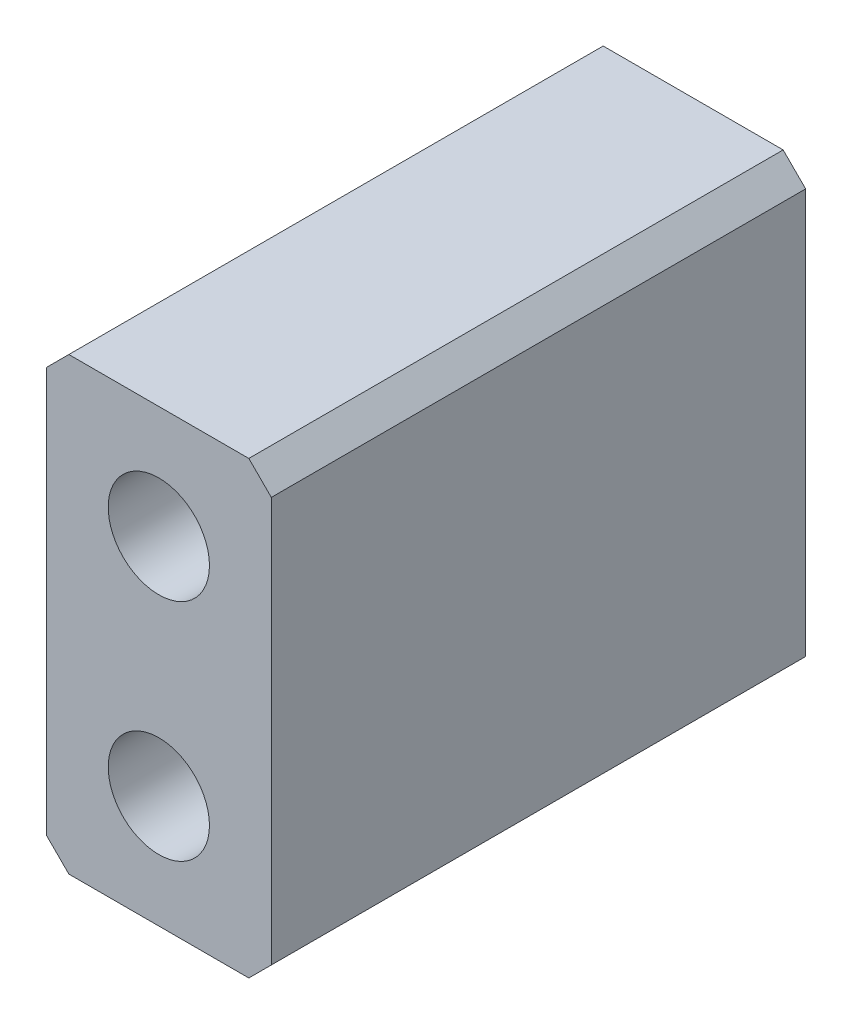
from build123d import *

# Parameters (mm, degrees)
SKETCH_1_W      = 20
SKETCH_1_H      = 40
SKETCH_1_R      = 4.5
EXTRUDE_1_DEPTH = 47.5
CHAMFER_1_SIZE  = 2
CHAMFER_2_SIZE  = 2


with BuildPart() as part:
    # 草图1 → 凸台-拉伸1 (new body)
    with BuildSketch(Plane.XY):
        Rectangle(SKETCH_1_W, SKETCH_1_H)
        with Locations((0, 10)):
            Circle(SKETCH_1_R, mode=Mode.SUBTRACT)
        with Locations((0, -10)):
            Circle(SKETCH_1_R, mode=Mode.SUBTRACT)
    extrude(amount=EXTRUDE_1_DEPTH)

    # 倒角1
    chamfer_1_edges = [part.edges().sort_by_distance(p)[0] for p in [
        (-10, -20, 23.75),
    ]]
    chamfer(chamfer_1_edges, length=CHAMFER_1_SIZE)

    # 倒角2
    chamfer_2_edges = [part.edges().sort_by_distance(p)[0] for p in [
        (10, -20, 23.75),
        (-10, 20, 23.75),
        (10, 20, 23.75),
    ]]
    chamfer(chamfer_2_edges, length=CHAMFER_2_SIZE)


solid = part.part
